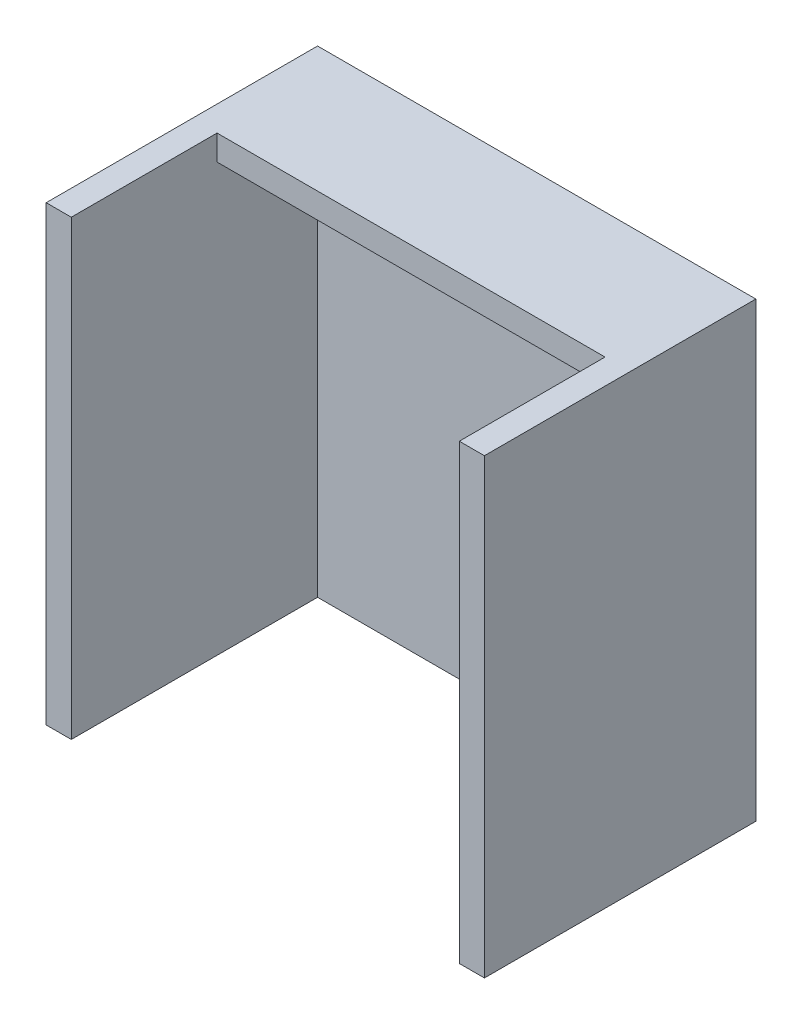
from build123d import *

# Parameters (mm, degrees)
SKETCH1_W           = 55.372
SKETCH1_H           = 57.15
BOSS_EXTRUDE1_DEPTH = 34.29
SHELL1_T            = -3.175
CUT_EXTRUDE1_DEPTH  = 39.116


with BuildPart() as part:
    # Sketch1 → Boss-Extrude1 (new body)
    with BuildSketch(Plane.XY):
        with Locations((6.35, 5.207)):
            Rectangle(SKETCH1_W, SKETCH1_H)
    extrude(amount=BOSS_EXTRUDE1_DEPTH)

    # Shell1
    shell1_openings = [part.faces().sort_by_distance(p)[0] for p in [
        (6.35, 5.207, 34.29),
        (6.35, -23.368, 17.145),
    ]]
    offset(amount=SHELL1_T, openings=shell1_openings, kind=Kind.INTERSECTION)

    # Sketch2 → Cut-Extrude1 (cut)
    with BuildSketch(Plane.XZ.offset(-30.607)):
        Polygon((-18.161, 15.875), (10.564637788, 15.875), (30.861, 15.875), (30.861, 34.29), (-18.161, 34.29), align=None)
    extrude(amount=-CUT_EXTRUDE1_DEPTH, mode=Mode.SUBTRACT)


solid = part.part
